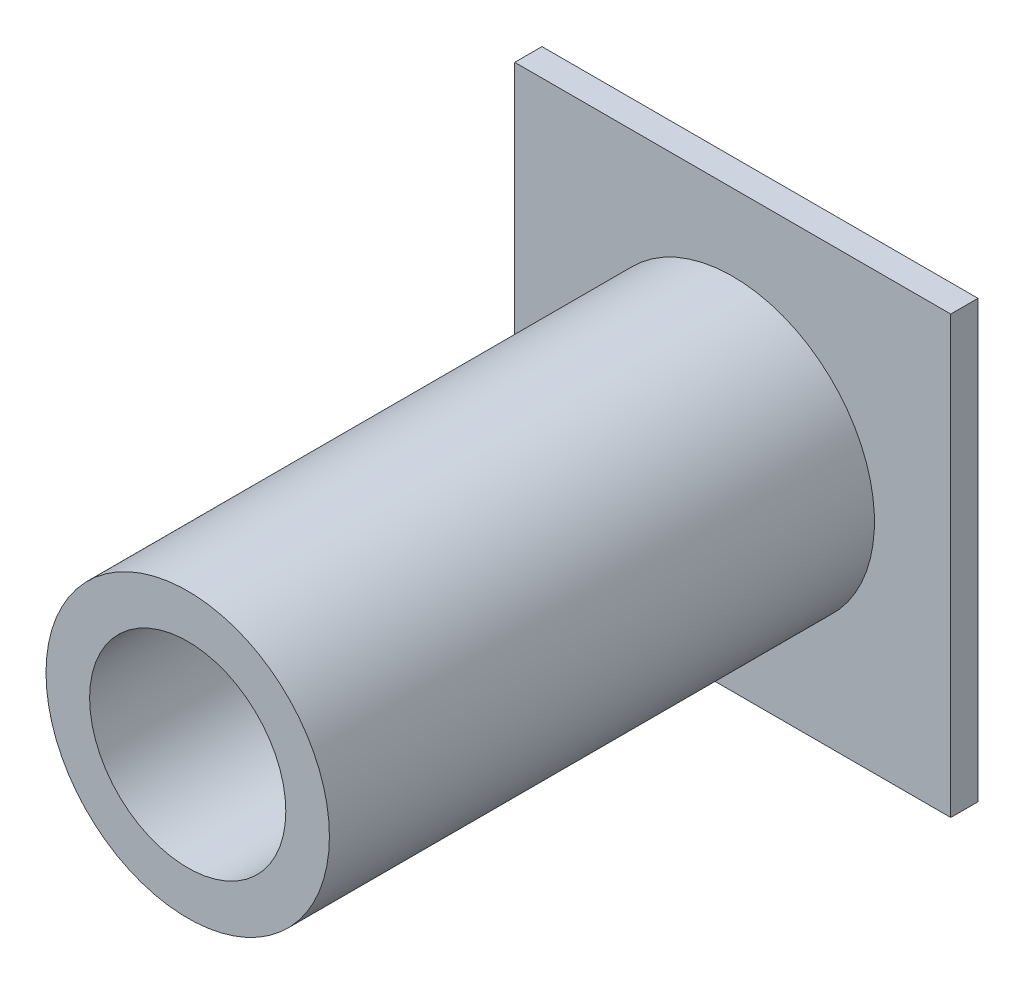
from build123d import *

# Parameters (mm, degrees)
SKETCH1_W           = 8
SKETCH1_H           = 8
BOSS_EXTRUDE1_DEPTH = 0.5
SKETCH4_R           = 2.6
BOSS_EXTRUDE3_DEPTH = 10
SKETCH6_R           = 1.8
CUT_EXTRUDE2_DEPTH  = 10


with BuildPart() as part:
    # Sketch1 → Boss-Extrude1 (new body)
    with BuildSketch(Plane.XY):
        Rectangle(SKETCH1_W, SKETCH1_H)
    extrude(amount=BOSS_EXTRUDE1_DEPTH)

    # Sketch4 → Boss-Extrude3 (add)
    with BuildSketch(Plane.XY.offset(0.5)):
        Circle(SKETCH4_R)
    extrude(amount=BOSS_EXTRUDE3_DEPTH)

    # Sketch6 → Cut-Extrude2 (cut)
    with BuildSketch(Plane.XY.offset(10.5)):
        Circle(SKETCH6_R)
    extrude(amount=-CUT_EXTRUDE2_DEPTH, mode=Mode.SUBTRACT)


solid = part.part
